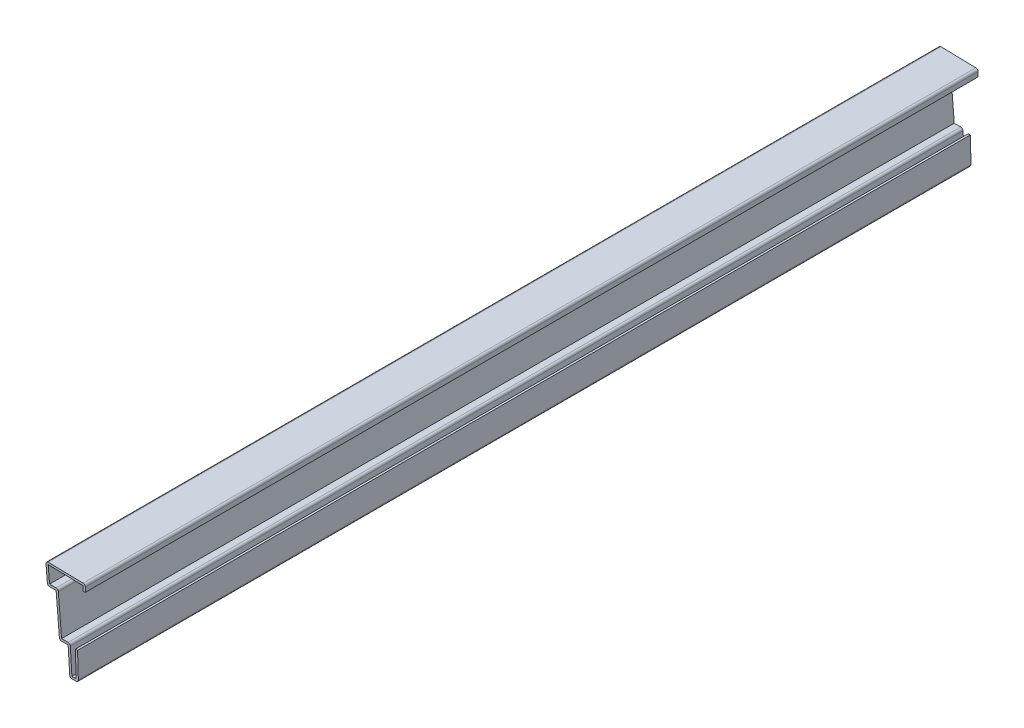
from build123d import *

# Parameters (mm, degrees)
EXTRUDE_THIN1_DEPTH = 412.75
FILLET1_R           = 1.016


with BuildPart() as part:
    # Sketch1 → Extrude-Thin1 (new body)
    with BuildSketch(Plane.XY):
        Polygon((3.175, 37.703125), (3.175, 40.878125), (-15.08125, 41.275), (-14.2875, 31.75), (-10.31875, 31.75), (-8.73125, 12.7), (-4.7625, 12.7), (-3.96875, 0), (0, 0), (-0.396875, 12.7), (-1.412379269, 12.668265492), (-1.048245973, 1.016), (-3.014267559, 1.016), (-3.808017559, 13.716), (-7.796394992, 13.716), (-9.383894992, 32.766), (-13.352644992, 32.766), (-13.975037647, 40.234711858), (2.159, 39.883971909), (2.159, 37.703125), align=None)
    extrude(amount=-EXTRUDE_THIN1_DEPTH)

    # Fillet1
    fillet1_edges = [part.edges().sort_by_distance(p)[0] for p in [
        (-9.383894992, 32.766, -206.375),
        (-3.808017559, 13.716, -206.375),
        (0, 0, -206.375),
        (-3.96875, 0, -206.375),
        (-8.73125, 12.7, -206.375),
        (-14.2875, 31.75, -206.375),
        (-15.08125, 41.275, -206.375),
        (3.175, 40.878125, -206.375),
    ]]
    fillet(fillet1_edges, radius=FILLET1_R)


solid = part.part
